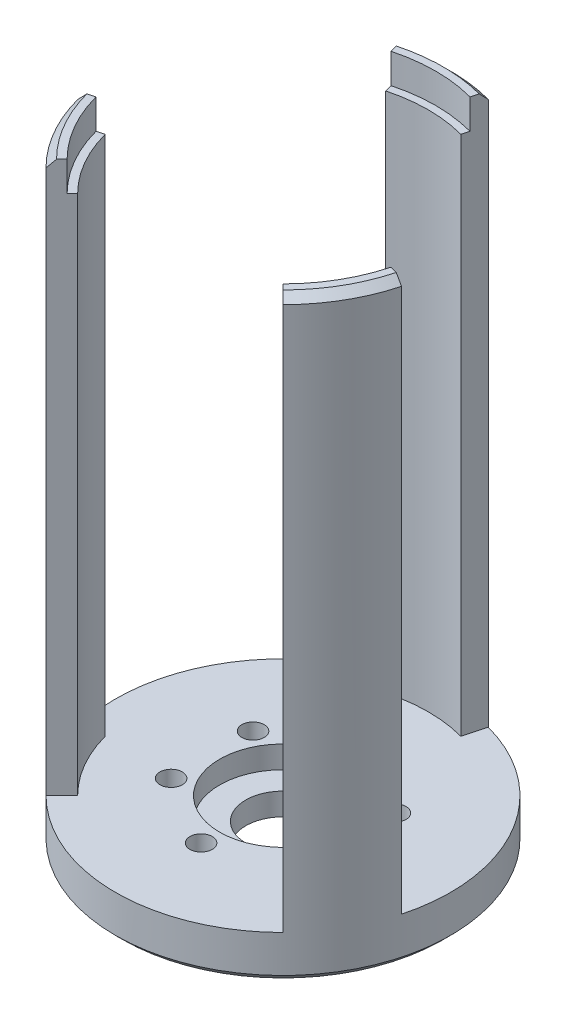
from build123d import *

# Parameters (mm, degrees)
SKETCH1_R           = 22.5
SKETCH1_R_2         = 1.5
SKETCH1_R_3         = 5
BOSS_EXTRUDE1_DEPTH = 6
SKETCH4_R           = 8.5
CUT_EXTRUDE2_DEPTH  = 3
SKETCH6_R           = 3.25
CUT_EXTRUDE3_DEPTH  = 2.5
BOSS_EXTRUDE2_DEPTH = 74
SKETCH7_R           = 20.5
CUT_EXTRUDE4_DEPTH  = 4
CHAMFER2_SIZE       = 1


with BuildPart() as part:
    # Sketch1 → Boss-Extrude1 (new body)
    with BuildSketch(Plane(origin=(0, 0, 0), x_dir=(1, 0, 0), z_dir=(0, 1, 0))):
        Circle(SKETCH1_R)
        with Locations((0, 11)):
            Circle(SKETCH1_R_2, mode=Mode.SUBTRACT)
        with Locations((9.526279442, 5.5)):
            Circle(SKETCH1_R_2, mode=Mode.SUBTRACT)
        with Locations((9.526279442, -5.5)):
            Circle(SKETCH1_R_2, mode=Mode.SUBTRACT)
        with Locations((0, -11)):
            Circle(SKETCH1_R_2, mode=Mode.SUBTRACT)
        with Locations((-9.526279442, -5.5)):
            Circle(SKETCH1_R_2, mode=Mode.SUBTRACT)
        with Locations((-9.526279442, 5.5)):
            Circle(SKETCH1_R_2, mode=Mode.SUBTRACT)
        Circle(SKETCH1_R_3, mode=Mode.SUBTRACT)
    extrude(amount=BOSS_EXTRUDE1_DEPTH)

    # Sketch4 → Cut-Extrude2 (cut)
    with BuildSketch(Plane(origin=(0, 6, 0), x_dir=(1, 0, 0), z_dir=(0, 1, 0))):
        Circle(SKETCH4_R)
    extrude(amount=-CUT_EXTRUDE2_DEPTH, mode=Mode.SUBTRACT)

    # Sketch6 → Cut-Extrude3 (cut)
    with BuildSketch(Plane.XZ):
        with Locations((0, 11)):
            Circle(SKETCH6_R)
        with Locations((9.526279442, -5.5)):
            Circle(SKETCH6_R)
        with Locations((-9.526279442, -5.5)):
            Circle(SKETCH6_R)
    extrude(amount=-CUT_EXTRUDE3_DEPTH, mode=Mode.SUBTRACT)

    # Sketch2 → Boss-Extrude2 (add)
    with BuildSketch(Plane(origin=(0, 6, 0), x_dir=(1, 0, 0), z_dir=(0, 1, 0))):
        with BuildLine():
            Line((5.046971379, 18.835553613), (5.823428515, 21.733331092))
            ThreePointArc((5.823428515, 21.733331092), (0, 22.5), (-5.823428515, 21.733331092))
            Line((-5.823428515, 21.733331092), (-5.046971379, 18.835553613))
            ThreePointArc((-5.046971379, 18.835553613), (0, 19.5), (5.046971379, 18.835553613))
        make_face()
        with BuildLine():
            Line((18.835553613, -5.046971379), (21.733331092, -5.823428515))
            ThreePointArc((21.733331092, -5.823428515), (19.485571585, -11.25), (15.909902577, -15.909902577))
            Line((15.909902577, -15.909902577), (13.788582233, -13.788582233))
            ThreePointArc((13.788582233, -13.788582233), (16.887495374, -9.75), (18.835553613, -5.046971379))
        make_face()
        with BuildLine():
            Line((-13.788582233, -13.788582233), (-15.909902577, -15.909902577))
            ThreePointArc((-15.909902577, -15.909902577), (-19.485571585, -11.25), (-21.733331092, -5.823428515))
            Line((-21.733331092, -5.823428515), (-18.835553613, -5.046971379))
            ThreePointArc((-18.835553613, -5.046971379), (-16.887495374, -9.75), (-13.788582233, -13.788582233))
        make_face()
    extrude(amount=BOSS_EXTRUDE2_DEPTH)

    # Sketch7 → Cut-Extrude4 (cut)
    with BuildSketch(Plane(origin=(0, 80, 0), x_dir=(1, 0, 0), z_dir=(0, 1, 0))):
        Circle(SKETCH7_R)
    extrude(amount=-CUT_EXTRUDE4_DEPTH, mode=Mode.SUBTRACT)

    # Chamfer2
    chamfer2_edges = [part.edges().sort_by_distance(p)[0] for p in [
        (-22.5, 0, 0),
        (19.485571585, 80, 11.25),
        (0, 80, -22.5),
        (-19.485571585, 80, 11.25),
    ]]
    chamfer(chamfer2_edges, length=CHAMFER2_SIZE)


solid = part.part
